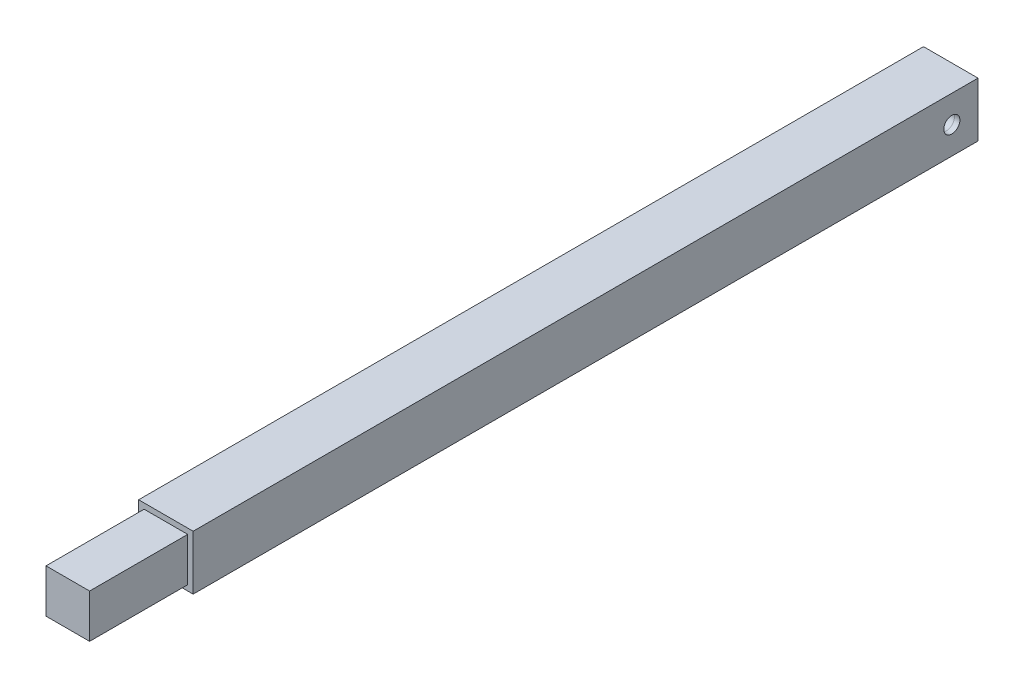
from build123d import *

# Parameters (mm, degrees)
SKETCH1_W          = 31.75
SKETCH1_H          = 31.75
SKETCH1_W_2        = 25.4
SKETCH1_H_2        = 25.4
EXTRUDE1_DEPTH     = 457.2
SKETCH2_W          = 25.4
SKETCH2_H          = 25.4
EXTRUDE2_DEPTH     = 57.15
SKETCH4_W          = 25.4
SKETCH4_H          = 25.4
EXTRUDE4_DEPTH     = 31.75
SKETCH3_R          = 4.699
CUT_EXTRUDE3_DEPTH = 32.75
SKETCH5_R          = 1.0795
CUT_EXTRUDE4_DEPTH = 15.24


with BuildPart() as part:
    # Sketch1 → Extrude1 (new body)
    with BuildSketch(Plane.XY):
        Rectangle(SKETCH1_W, SKETCH1_H)
        Rectangle(SKETCH1_W_2, SKETCH1_H_2, mode=Mode.SUBTRACT)
    extrude(amount=EXTRUDE1_DEPTH)


with BuildPart() as body_2:
    # Sketch2 → Extrude2 (new body)
    with BuildSketch(Plane.XY.offset(457.2)):
        Rectangle(SKETCH2_W, SKETCH2_H)
    extrude(amount=EXTRUDE2_DEPTH)


with BuildPart() as body_3:
    # Sketch4 → Extrude4 (new body)
    with BuildSketch(Plane(origin=(0, 0, 0), x_dir=(-1, 0, 0), z_dir=(0, 0, -1))):
        Rectangle(SKETCH4_W, SKETCH4_H)
    extrude(amount=-EXTRUDE4_DEPTH)


with BuildPart() as cut_extrude3_tool:
    # Sketch3 → Cut-Extrude3 (new body, through all)
    with BuildSketch(Plane.ZY.offset(15.875)):
        with Locations((15.24, 0)):
            Circle(SKETCH3_R)
    extrude(amount=-CUT_EXTRUDE3_DEPTH)


with BuildPart() as part_1:
    add(part.part)

    # Cut-Extrude3: cut by cut_extrude3_tool
    add(cut_extrude3_tool.part, mode=Mode.SUBTRACT)


with BuildPart() as body_3_1:
    add(body_3.part)

    # Cut-Extrude3: cut by cut_extrude3_tool
    add(cut_extrude3_tool.part, mode=Mode.SUBTRACT)

    # Sketch5 → Cut-Extrude4 (cut)
    with BuildSketch(Plane(origin=(0, 0, 0), x_dir=(-1, 0, 0), z_dir=(0, 0, -1))):
        Circle(SKETCH5_R)
    extrude(amount=-CUT_EXTRUDE4_DEPTH, mode=Mode.SUBTRACT)


solid = Compound([body_2.part, part_1.part, body_3_1.part])
